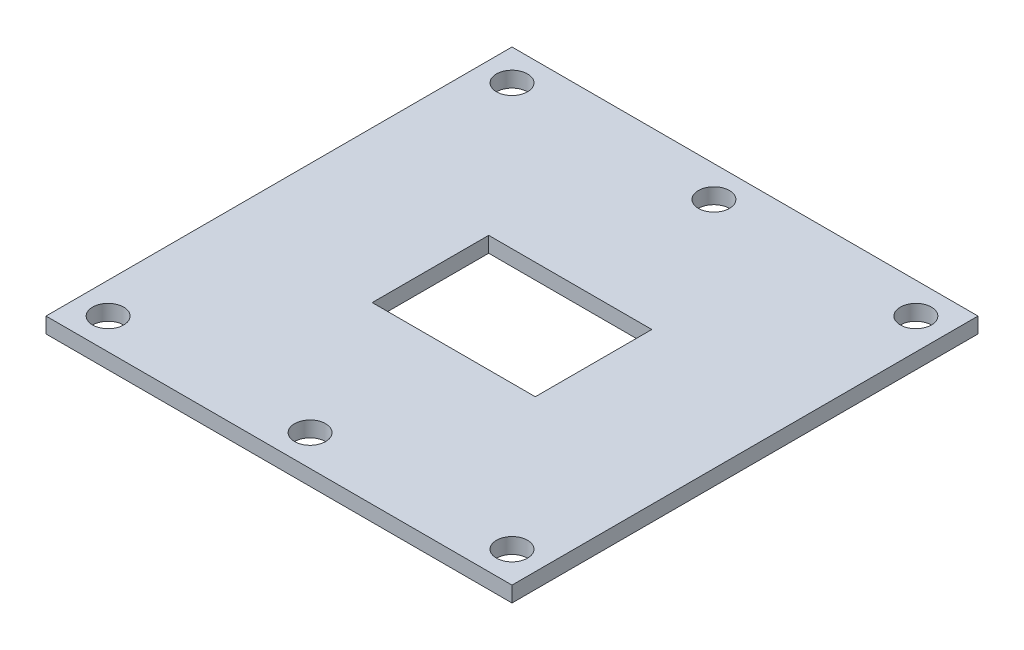
from build123d import *

# Parameters (mm, degrees)
SKETCH1_W           = 60
SKETCH1_H           = 60
BOSS_EXTRUDE1_DEPTH = 2
SKETCH2_R           = 2
CUT_EXTRUDE1_DEPTH  = 3
SKETCH3_W           = 21
SKETCH3_H           = 15
CUT_EXTRUDE2_DEPTH  = 2


with BuildPart() as part:
    # Sketch1 → Boss-Extrude1 (new body)
    with BuildSketch(Plane(origin=(0, 0, 0), x_dir=(1, 0, 0), z_dir=(0, 1, 0))):
        Rectangle(SKETCH1_W, SKETCH1_H)
    extrude(amount=BOSS_EXTRUDE1_DEPTH)

    # Sketch2 → Cut-Extrude1 (cut, through all)
    with BuildSketch(Plane(origin=(0, 2, 0), x_dir=(1, 0, 0), z_dir=(0, 1, 0))):
        with Locations((-26, 26)):
            Circle(SKETCH2_R)
        with Locations((0, 26)):
            Circle(SKETCH2_R)
        with Locations((26, 26)):
            Circle(SKETCH2_R)
        with Locations((26, -26)):
            Circle(SKETCH2_R)
        with Locations((0, -26)):
            Circle(SKETCH2_R)
        with Locations((-26, -26)):
            Circle(SKETCH2_R)
    extrude(amount=-CUT_EXTRUDE1_DEPTH, mode=Mode.SUBTRACT)

    # Sketch3 → Cut-Extrude2 (cut)
    with BuildSketch(Plane(origin=(0, 2, 0), x_dir=(1, 0, 0), z_dir=(0, 1, 0))):
        Rectangle(SKETCH3_W, SKETCH3_H)
    extrude(amount=-CUT_EXTRUDE2_DEPTH, mode=Mode.SUBTRACT)


solid = part.part
